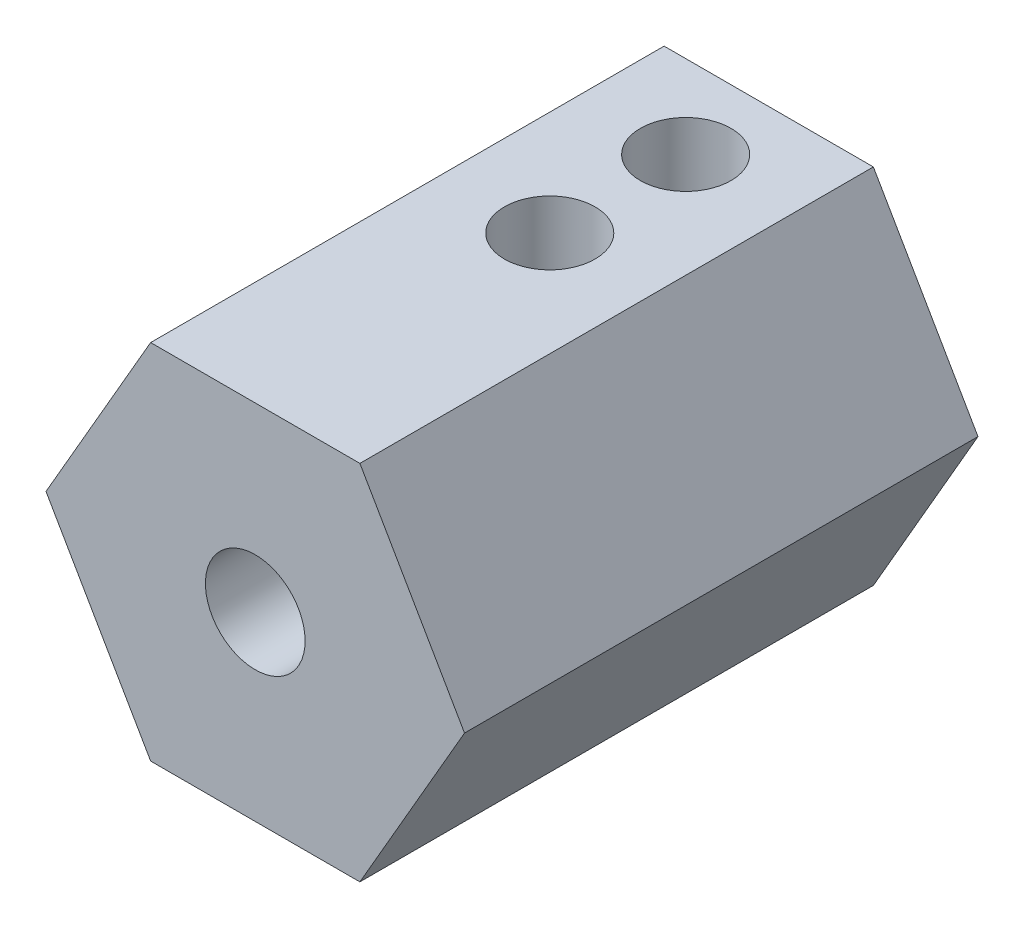
from build123d import *

# Parameters (mm, degrees)
BOSS_EXTRUDE1_DEPTH        = 8.5
CUT_EXTRUDE1_START         = -10
SKETCH2_R                  = 2
CUT_EXTRUDE1_DEPTH         = 10
M4X0_7_TAPPED_HOLE1_D      = 3.3
M4X0_7_TAPPED_HOLE1_DEPTH  = 7
M4X0_7_TAPPED_HOLE1_TIP    = 0.991420021
M3X0_5_TAPPED_HOLE1_REACH  = 18.256
M3X0_5_TAPPED_HOLE1_BORE_R = 1.5


with BuildPart() as part:
    # Sketch1 → Boss-Extrude1 (new, symmetric)
    with BuildSketch(Plane.XY):
        Polygon((3.464101615, 6), (-3.464101615, 6), (-6.92820323, 0), (-3.464101615, -6), (3.464101615, -6), (6.92820323, 0), align=None)
    extrude(amount=BOSS_EXTRUDE1_DEPTH, both=True)

    # Sketch2 → Cut-Extrude1 (cut)
    with BuildSketch(Plane(origin=(0, 0, -8.5), x_dir=(-1, 0, 0), z_dir=(0, 0, -1)).offset(CUT_EXTRUDE1_START)):
        Circle(SKETCH2_R)
    extrude(amount=CUT_EXTRUDE1_DEPTH, mode=Mode.SUBTRACT)

    # M4x0.7 Tapped Hole1
    with Locations(Plane.XY.offset(8.5)):
        with Locations((0, 0)):
            Hole(M4X0_7_TAPPED_HOLE1_D / 2, depth=M4X0_7_TAPPED_HOLE1_DEPTH)
            with Locations((0, 0, -(M4X0_7_TAPPED_HOLE1_DEPTH + M4X0_7_TAPPED_HOLE1_TIP / 2))):  # 118° drill point
                Cone(0, M4X0_7_TAPPED_HOLE1_D / 2, M4X0_7_TAPPED_HOLE1_TIP, mode=Mode.SUBTRACT)

    # M3x0.5 Tapped Hole1 bore → M3x0.5 Tapped Hole1 (cut, up to next)
    with BuildSketch(Plane(origin=(0, 6, 0), x_dir=(1, 0, 0), z_dir=(0, 1, 0)), mode=Mode.PRIVATE) as m3x0_5_tapped_hole1_sk1:
        with Locations((0, 5.75)):
            Circle(M3X0_5_TAPPED_HOLE1_BORE_R)
    m3x0_5_tapped_hole1_tool1 = extrude(m3x0_5_tapped_hole1_sk1.sketch, amount=-M3X0_5_TAPPED_HOLE1_REACH, mode=Mode.PRIVATE) & part.part
    # M3x0.5 Tapped Hole1 bore → M3x0.5 Tapped Hole1 (cut, up to next)
    with BuildSketch(Plane(origin=(0, 6, 0), x_dir=(1, 0, 0), z_dir=(0, 1, 0)), mode=Mode.PRIVATE) as m3x0_5_tapped_hole1_sk2:
        with Locations((0, 1.25)):
            Circle(M3X0_5_TAPPED_HOLE1_BORE_R)
    m3x0_5_tapped_hole1_tool2 = extrude(m3x0_5_tapped_hole1_sk2.sketch, amount=-M3X0_5_TAPPED_HOLE1_REACH, mode=Mode.PRIVATE) & part.part
    add(m3x0_5_tapped_hole1_tool1.solids().sort_by_distance((0, 6, -5.75))[0], mode=Mode.SUBTRACT)
    add(m3x0_5_tapped_hole1_tool2.solids().sort_by_distance((0, 6, -1.25))[0], mode=Mode.SUBTRACT)


solid = part.part
